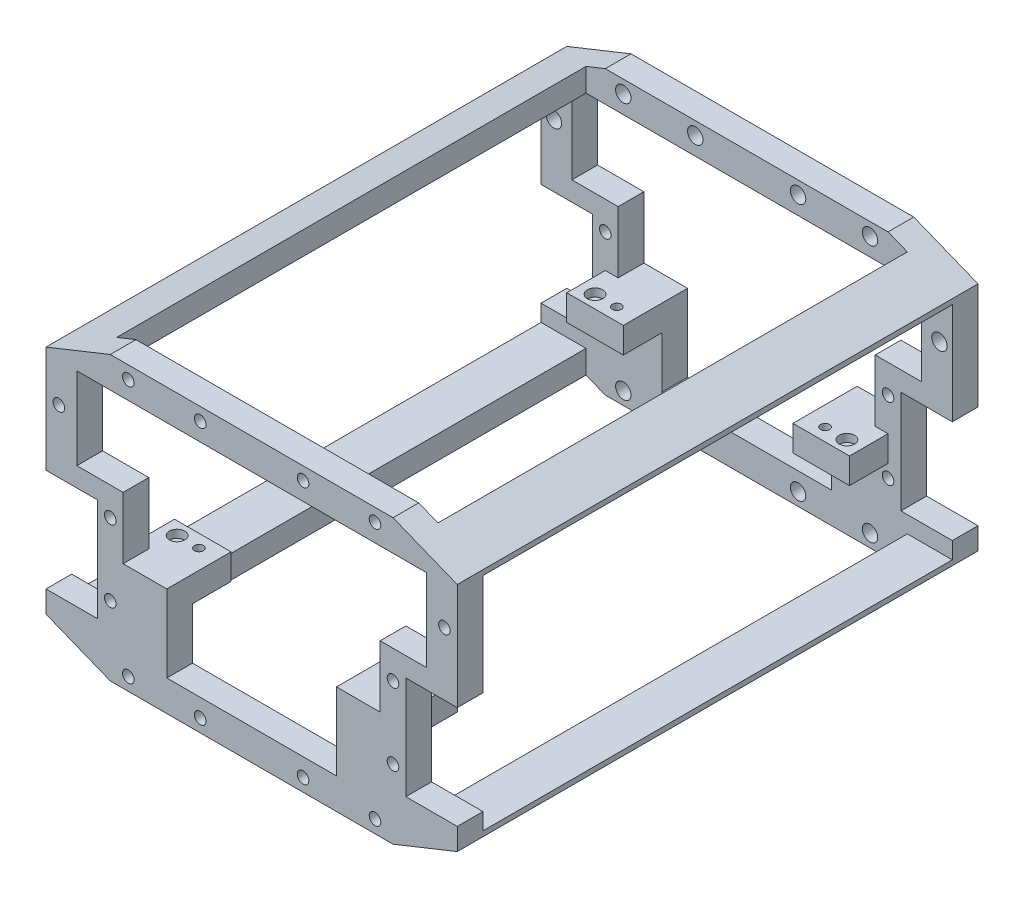
from build123d import *

# Parameters (mm, degrees)
SKETCH1_R                 = 2.25
BOSS_EXTRUDE2_DEPTH       = 202.6
SKETCH2_W                 = 182.6
SKETCH2_H                 = 86
CUT_EXTRUDE1_DEPTH        = 161
SKETCH4_R                 = 3
CUT_EXTRUDE2_DEPTH        = 4.5
CUT_EXTRUDE3_START        = 182.6
SKETCH4_2_R               = 3
CUT_EXTRUDE3_DEPTH        = 4.5
SKETCH3_W                 = 110
SKETCH3_H                 = 182.6
CUT_EXTRUDE4_DEPTH        = 111
CUT_EXTRUDE5_START        = -12
SKETCH5_W                 = 125
SKETCH5_H                 = 182.6
CUT_EXTRUDE5_DEPTH        = 111
SKETCH6_W                 = 20
SKETCH6_H                 = 40
CUT_EXTRUDE7_DEPTH        = 12
SKETCH8_R                 = 2.25
BOSS_EXTRUDE3_DEPTH       = 10
BOSS_EXTRUDE4_START       = -192.6
SKETCH8_2_R               = 2.25
BOSS_EXTRUDE4_DEPTH       = 10
BOSS_EXTRUDE5_START       = 30
SKETCH9_W                 = 2
SKETCH9_H                 = 10
SKETCH9_W_2               = 15
SKETCH9_H_2               = 5
SKETCH9_R                 = 1.75
BOSS_EXTRUDE5_DEPTH       = 10
SKETCH10_W                = 22
SKETCH10_H                = 10
BOSS_EXTRUDE6_DEPTH       = 20
MIRROR3_START             = 30
MIRROR3_COPY_1_SKETCH_W   = 2
MIRROR3_COPY_1_SKETCH_H   = 10
MIRROR3_COPY_1_SKETCH_W_2 = 15
MIRROR3_COPY_1_SKETCH_H_2 = 5
MIRROR3_COPY_1_SKETCH_R   = 1.75
MIRROR3_COPY_1_DEPTH      = 10
MIRROR3_COPY_2_SKETCH_W   = 22
MIRROR3_COPY_2_SKETCH_H   = 10
MIRROR3_COPY_2_DEPTH      = 20
SKETCH11_R                = 2.25
CUT_EXTRUDE8_DEPTH        = 203.6
SKETCH12_R                = 3
CUT_EXTRUDE9_DEPTH        = 3.1


with BuildPart() as part:
    # Sketch1 → Boss-Extrude2 (new body)
    with BuildSketch(Plane.XY):
        Polygon((-48.624838984, -50.035732152), (61.375161016, -50.035732152), (86.375161016, -40.035732152), (86.375161016, 49.964267848), (61.375161016, 59.964267848), (-48.624838984, 59.964267848), (-73.624838984, 49.964267848), (-73.624838984, -40.035732152), align=None)
        with Locations((-41.624838984, -45.035732152)):
            Circle(SKETCH1_R, mode=Mode.SUBTRACT)
        with Locations((-68.624838984, -23.035732152)):
            Circle(SKETCH1_R, mode=Mode.SUBTRACT)
        with Locations((-13.624838984, -45.035732152)):
            Circle(SKETCH1_R, mode=Mode.SUBTRACT)
        with Locations((-68.624838984, 4.964267848)):
            Circle(SKETCH1_R, mode=Mode.SUBTRACT)
        with Locations((26.375161016, -45.035732152)):
            Circle(SKETCH1_R, mode=Mode.SUBTRACT)
        with Locations((54.375161016, -45.035732152)):
            Circle(SKETCH1_R, mode=Mode.SUBTRACT)
        with Locations((81.375161016, -23.035732152)):
            Circle(SKETCH1_R, mode=Mode.SUBTRACT)
        Polygon((74.375161016, 47.964267848), (74.375161016, -38.035732152), (13.375161016, -38.035732152), (-0.624838984, -38.035732152), (-61.624838984, -38.035732152), (-61.624838984, 47.964267848), (-7.624838984, 47.964267848), (-0.624838984, 47.964267848), (13.375161016, 47.964267848), (20.375161016, 47.964267848), align=None, mode=Mode.SUBTRACT)
        with Locations((81.375161016, 4.964267848)):
            Circle(SKETCH1_R, mode=Mode.SUBTRACT)
        with Locations((-68.624838984, 32.964267848)):
            Circle(SKETCH1_R, mode=Mode.SUBTRACT)
        with Locations((-41.624838984, 54.964267848)):
            Circle(SKETCH1_R, mode=Mode.SUBTRACT)
        with Locations((-13.624838984, 54.964267848)):
            Circle(SKETCH1_R, mode=Mode.SUBTRACT)
        with Locations((26.375161016, 54.964267848)):
            Circle(SKETCH1_R, mode=Mode.SUBTRACT)
        with Locations((81.375161016, 32.964267848)):
            Circle(SKETCH1_R, mode=Mode.SUBTRACT)
        with Locations((54.375161016, 54.964267848)):
            Circle(SKETCH1_R, mode=Mode.SUBTRACT)
    extrude(amount=BOSS_EXTRUDE2_DEPTH)

    # Sketch2 → Cut-Extrude1 (cut, through all)
    with BuildSketch(Plane.ZY.offset(73.624838984)):
        with Locations((101.3, 4.964267848)):
            Rectangle(SKETCH2_W, SKETCH2_H)
    extrude(amount=-CUT_EXTRUDE1_DEPTH, mode=Mode.SUBTRACT)

    # Sketch4 → Cut-Extrude2 (cut)
    with BuildSketch(Plane.XY.offset(10)):
        with Locations((-68.624838984, 32.964267848)):
            Circle(SKETCH4_R)
        with Locations((-68.624838984, 4.964267848)):
            Circle(SKETCH4_R)
        with Locations((-68.624838984, -23.035732152)):
            Circle(SKETCH4_R)
        with Locations((-41.624838984, 54.964267848)):
            Circle(SKETCH4_R)
        with Locations((-13.624838984, 54.964267848)):
            Circle(SKETCH4_R)
        with Locations((26.375161016, 54.964267848)):
            Circle(SKETCH4_R)
        with Locations((54.375161016, 54.964267848)):
            Circle(SKETCH4_R)
        with Locations((81.375161016, 32.964267848)):
            Circle(SKETCH4_R)
        with Locations((81.375161016, 4.964267848)):
            Circle(SKETCH4_R)
        with Locations((81.375161016, -23.035732152)):
            Circle(SKETCH4_R)
        with Locations((54.375161016, -45.035732152)):
            Circle(SKETCH4_R)
        with Locations((26.375161016, -45.035732152)):
            Circle(SKETCH4_R)
        with Locations((-13.624838984, -45.035732152)):
            Circle(SKETCH4_R)
        with Locations((-41.624838984, -45.035732152)):
            Circle(SKETCH4_R)
    extrude(amount=-CUT_EXTRUDE2_DEPTH, mode=Mode.SUBTRACT)

    # Sketch4_2 → Cut-Extrude3 (cut)
    with BuildSketch(Plane.XY.offset(10).offset(CUT_EXTRUDE3_START)):
        with Locations((-68.624838984, 32.964267848)):
            Circle(SKETCH4_2_R)
        with Locations((-68.624838984, 4.964267848)):
            Circle(SKETCH4_2_R)
        with Locations((-68.624838984, -23.035732152)):
            Circle(SKETCH4_2_R)
        with Locations((-41.624838984, 54.964267848)):
            Circle(SKETCH4_2_R)
        with Locations((-13.624838984, 54.964267848)):
            Circle(SKETCH4_2_R)
        with Locations((26.375161016, 54.964267848)):
            Circle(SKETCH4_2_R)
        with Locations((54.375161016, 54.964267848)):
            Circle(SKETCH4_2_R)
        with Locations((81.375161016, 32.964267848)):
            Circle(SKETCH4_2_R)
        with Locations((81.375161016, 4.964267848)):
            Circle(SKETCH4_2_R)
        with Locations((81.375161016, -23.035732152)):
            Circle(SKETCH4_2_R)
        with Locations((54.375161016, -45.035732152)):
            Circle(SKETCH4_2_R)
        with Locations((26.375161016, -45.035732152)):
            Circle(SKETCH4_2_R)
        with Locations((-13.624838984, -45.035732152)):
            Circle(SKETCH4_2_R)
        with Locations((-41.624838984, -45.035732152)):
            Circle(SKETCH4_2_R)
    extrude(amount=CUT_EXTRUDE3_DEPTH, mode=Mode.SUBTRACT)

    # Sketch3 → Cut-Extrude4 (cut, through all)
    with BuildSketch(Plane(origin=(0, 59.964267848, 0), x_dir=(1, 0, 0), z_dir=(0, 1, 0))):
        with Locations((6.375161016, -101.3)):
            Rectangle(SKETCH3_W, SKETCH3_H)
    extrude(amount=-CUT_EXTRUDE4_DEPTH, mode=Mode.SUBTRACT)

    # Sketch5 → Cut-Extrude5 (cut, through all)
    with BuildSketch(Plane(origin=(0, -38.035732152, 0), x_dir=(1, 0, 0), z_dir=(0, 1, 0)).offset(CUT_EXTRUDE5_START)):
        with Locations((6.375161016, -101.3)):
            Rectangle(SKETCH5_W, SKETCH5_H)
    extrude(amount=CUT_EXTRUDE5_DEPTH, mode=Mode.SUBTRACT)

    # Sketch6 → Cut-Extrude7 (cut)
    with BuildSketch(Plane(origin=(86.375161016, 0, 0), x_dir=(0, 0, -1), z_dir=(1, 0, 0))):
        with Locations((-192.6, -11.535732152)):
            Rectangle(SKETCH6_W, SKETCH6_H)
        with Locations((-10, -11.535732152)):
            Rectangle(SKETCH6_W, SKETCH6_H)
    cut_extrude7 = extrude(amount=-CUT_EXTRUDE7_DEPTH, mode=Mode.SUBTRACT)

    # Sketch8 → Boss-Extrude3 (add)
    with BuildSketch(Plane.XY.offset(202.6)):
        Polygon((66.375161016, 8.464267848), (66.375161016, -31.535732152), (74.375161016, -31.535732152), (74.375161016, -38.035732152), (56.375161016, -38.035732152), (56.375161016, 15.998735889), (74.375161016, 15.998735889), (74.375161016, 8.464267848), align=None)
        with Locations((61.375161016, 4.964267848)):
            Circle(SKETCH8_R, mode=Mode.SUBTRACT)
        with Locations((61.375161016, -23.035732152)):
            Circle(SKETCH8_R, mode=Mode.SUBTRACT)
    boss_extrude3 = extrude(amount=-BOSS_EXTRUDE3_DEPTH)

    # Sketch8_2 → Boss-Extrude4 (add)
    with BuildSketch(Plane.XY.offset(202.6).offset(BOSS_EXTRUDE4_START)):
        Polygon((66.375161016, 8.464267848), (66.375161016, -31.535732152), (74.375161016, -31.535732152), (74.375161016, -38.035732152), (56.375161016, -38.035732152), (56.375161016, 15.998735889), (74.375161016, 15.998735889), (74.375161016, 8.464267848), align=None)
        with Locations((61.375161016, 4.964267848)):
            Circle(SKETCH8_2_R, mode=Mode.SUBTRACT)
        with Locations((61.375161016, -23.035732152)):
            Circle(SKETCH8_2_R, mode=Mode.SUBTRACT)
    boss_extrude4 = extrude(amount=-BOSS_EXTRUDE4_DEPTH)

    # Mirror1: Cut-Extrude7, Boss-Extrude3, Boss-Extrude4 across plane
    add(cut_extrude7.mirror(Plane(origin=(6.375161016, 0, 0), x_dir=(0, 0, 1), z_dir=(1, 0, 0))), mode=Mode.SUBTRACT)
    add(boss_extrude3.mirror(Plane(origin=(6.375161016, 0, 0), x_dir=(0, 0, 1), z_dir=(1, 0, 0))))
    add(boss_extrude4.mirror(Plane(origin=(6.375161016, 0, 0), x_dir=(0, 0, 1), z_dir=(1, 0, 0))))

    # Sketch9 → Boss-Extrude5 (add)
    with BuildSketch(Plane(origin=(0, -38.035732152, 0), x_dir=(1, 0, 0), z_dir=(0, 1, 0)).offset(BOSS_EXTRUDE5_START)):
        Polygon((-48.624838984, -25), (-41.624838984, -25), (-41.624838984, -15), (-41.624838984, -10), (-43.624838984, -10), (-43.624838984, 0), (-48.624838984, 0), align=None)
        with Locations((-42.624838984, -5)):
            Rectangle(SKETCH9_W, SKETCH9_H)
        with Locations((-34.124838984, -5)):
            Rectangle(SKETCH9_W_2, SKETCH9_H)
        with Locations((-34.124838984, -12.5)):
            Rectangle(SKETCH9_W_2, SKETCH9_H_2)
        with Locations((-34.124838984, -20)):
            Rectangle(SKETCH9_W_2, SKETCH9_H)
        with Locations((-34.124838984, -20)):
            Circle(SKETCH9_R, mode=Mode.SUBTRACT)
    boss_extrude5 = extrude(amount=-BOSS_EXTRUDE5_DEPTH)

    # Sketch10 → Boss-Extrude6 (add)
    with BuildSketch(Plane.XZ.offset(18.035732152)):
        with Locations((-37.624838984, 5)):
            Rectangle(SKETCH10_W, SKETCH10_H)
    boss_extrude6 = extrude(amount=BOSS_EXTRUDE6_DEPTH)

    # Mirror2: Boss-Extrude5, Boss-Extrude6 across plane
    add(boss_extrude5.mirror(Plane.XY.offset(101.3)))
    add(boss_extrude6.mirror(Plane.XY.offset(101.3)))

    # Mirror3: Boss-Extrude5, Boss-Extrude6 across plane
    add(boss_extrude5.mirror(Plane(origin=(6.375161016, 0, 0), x_dir=(0, 0, 1), z_dir=(1, 0, 0))))
    add(boss_extrude6.mirror(Plane(origin=(6.375161016, 0, 0), x_dir=(0, 0, 1), z_dir=(1, 0, 0))))

    # Mirror3 copy 1 sketch → Mirror3 copy 1 (add)
    with BuildSketch(Plane(origin=(12.750322031, -38.035732152, 202.6), x_dir=(-1, 0, 0), z_dir=(0, 1, 0)).offset(MIRROR3_START)):
        Polygon((-48.624838984, -25), (-41.624838984, -25), (-41.624838984, -15), (-41.624838984, -10), (-43.624838984, -10), (-43.624838984, 0), (-48.624838984, 0), align=None)
        with Locations((-42.624838984, -5)):
            Rectangle(MIRROR3_COPY_1_SKETCH_W, MIRROR3_COPY_1_SKETCH_H)
        with Locations((-34.124838984, -5)):
            Rectangle(MIRROR3_COPY_1_SKETCH_W_2, MIRROR3_COPY_1_SKETCH_H)
        with Locations((-34.124838984, -12.5)):
            Rectangle(MIRROR3_COPY_1_SKETCH_W_2, MIRROR3_COPY_1_SKETCH_H_2)
        with Locations((-34.124838984, -20)):
            Rectangle(MIRROR3_COPY_1_SKETCH_W_2, MIRROR3_COPY_1_SKETCH_H)
        with Locations((-34.124838984, -20)):
            Circle(MIRROR3_COPY_1_SKETCH_R, mode=Mode.SUBTRACT)
    extrude(amount=-MIRROR3_COPY_1_DEPTH)

    # Mirror3 copy 2 sketch → Mirror3 copy 2 (add)
    with BuildSketch(Plane(origin=(12.750322031, -18.035732152, 202.6), x_dir=(-1, 0, 0), z_dir=(0, -1, 0))):
        with Locations((-37.624838984, 5)):
            Rectangle(MIRROR3_COPY_2_SKETCH_W, MIRROR3_COPY_2_SKETCH_H)
    extrude(amount=MIRROR3_COPY_2_DEPTH)

    # Sketch11 → Cut-Extrude8 (cut, through all)
    with BuildSketch(Plane.XY.offset(202.6)):
        with Locations((-48.624838984, -23.035732152)):
            Circle(SKETCH11_R)
        with Locations((61.375161016, -23.035732152)):
            Circle(SKETCH11_R)
    extrude(amount=-CUT_EXTRUDE8_DEPTH, mode=Mode.SUBTRACT)

    # Sketch12 → Cut-Extrude9 (cut)
    with BuildSketch(Plane(origin=(0, -8.035732152, 0), x_dir=(1, 0, 0), z_dir=(0, 1, 0))):
        with Locations((-42.624838984, -20)):
            Circle(SKETCH12_R)
        with Locations((55.375161016, -20)):
            Circle(SKETCH12_R)
        with Locations((55.375161016, -182.6)):
            Circle(SKETCH12_R)
        with Locations((-42.624838984, -182.6)):
            Circle(SKETCH12_R)
    extrude(amount=-CUT_EXTRUDE9_DEPTH, mode=Mode.SUBTRACT)


solid = part.part
